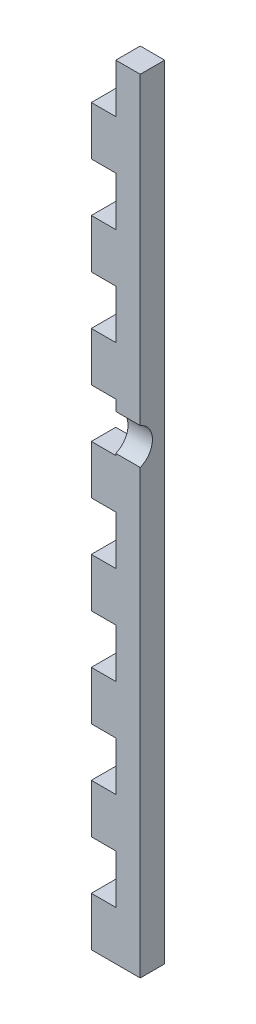
from build123d import *

# Parameters (mm, degrees)
SALIENTE_EXTRUIR1_DEPTH = 5
CROQUIS3_R              = 4
CORTAR_EXTRUIR1_DEPTH   = 5


with BuildPart() as part:
    # Croquis1 → Saliente-Extruir1 (new body)
    with BuildSketch(Plane.XY):
        Polygon((-10.50310955, 63.111111111), (-10.50310955, 53.111111111), (-5.50310955, 53.111111111), (-5.50310955, 43.111111111), (-10.50310955, 43.111111111), (-10.50310955, 33.111111111), (-5.50310955, 33.111111111), (-5.50310955, 23.111111111), (-10.50310955, 23.111111111), (-10.50310955, 13.111111111), (-5.50310955, 13.111111111), (-5.50310955, 3.111111111), (-10.50310955, 3.111111111), (-10.50310955, -6.888888889), (-5.50310955, -6.888888889), (-5.50310955, -16.888888889), (-10.50310955, -16.888888889), (-10.50310955, -26.888888889), (-5.50310955, -26.888888889), (-5.50310955, -36.888888889), (-10.50310955, -36.888888889), (-10.50310955, -46.888888889), (-5.50310955, -46.888888889), (-5.50310955, -56.888888889), (-10.50310955, -56.888888889), (-10.50310955, -66.888888889), (-5.50310955, -66.888888889), (-5.50310955, -76.888888889), (-10.50310955, -76.888888889), (-10.50310955, -86.888888889), (-0.50310955, -86.888888889), (-0.50310955, 73.111111111), (-5.50310955, 73.111111111), (-5.50310955, 63.111111111), align=None)
    extrude(amount=SALIENTE_EXTRUIR1_DEPTH)

    # Croquis3 → Cortar-Extruir1 (cut)
    with BuildSketch(Plane.ZY.offset(5.50310955)):
        with Locations((6.5, 7.201111111)):
            Circle(CROQUIS3_R)
    extrude(amount=-CORTAR_EXTRUIR1_DEPTH, mode=Mode.SUBTRACT)


solid = part.part
